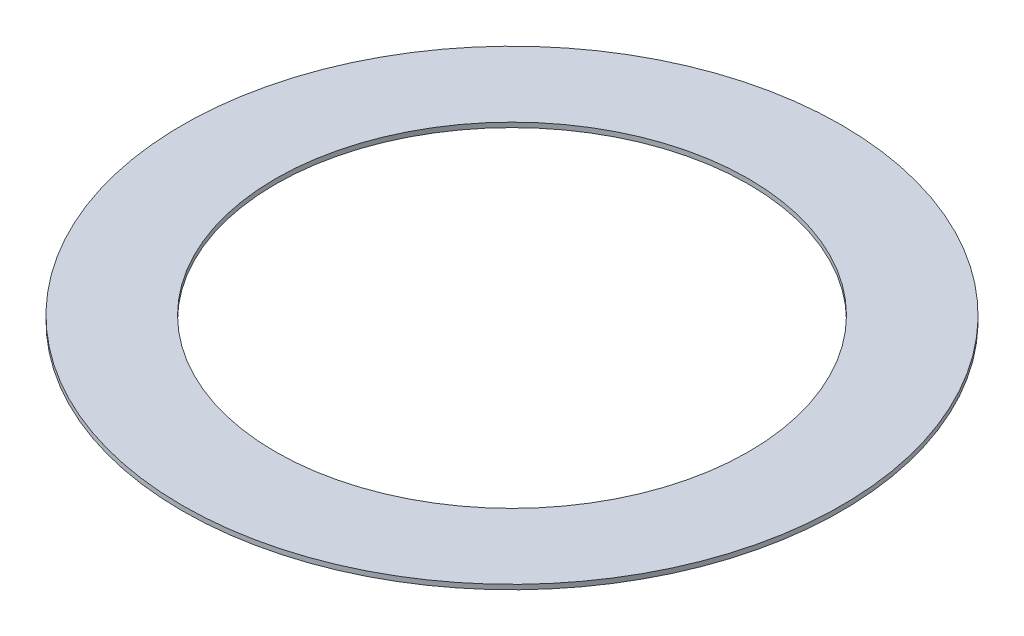
from build123d import *

# Parameters (mm, degrees)
SKETCH1_R      = 10.45
SKETCH1_R_2    = 7.5
EXTRUDE1_DEPTH = 0.15


with BuildPart() as part:
    # Sketch1 → Extrude1 (new body)
    with BuildSketch(Plane(origin=(0, 0, 0), x_dir=(1, 0, 0), z_dir=(0, 1, 0))):
        with Locations(Location((0, 0, 0), (0, 0, 270))):  # turned: the seam where the file's is
            Circle(SKETCH1_R)
        with Locations(Location((0, 0, 0), (0, 0, 270))):  # turned: the seam where the file's is
            Circle(SKETCH1_R_2, mode=Mode.SUBTRACT)
    extrude(amount=EXTRUDE1_DEPTH)


solid = part.part
